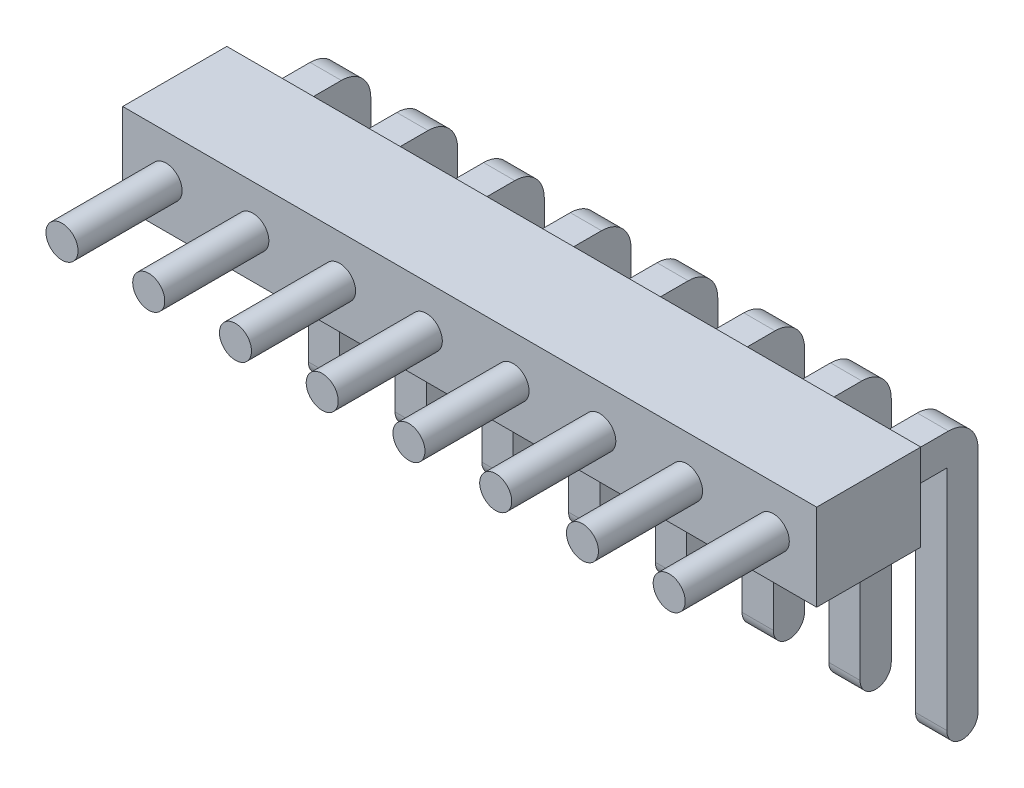
from build123d import *

# Parameters (mm, degrees)
CROQUIS1_W              = 20
CROQUIS1_H              = 2.5
SALIENTE_EXTRUIR1_DEPTH = 3
CROQUIS2_R              = 0.461571169
SALIENTE_EXTRUIR2_DEPTH = 3
MATRIZL1_COUNT          = 8
MATRIZL1_PITCH          = 2.5
SALIENTE_EXTRUIR3_DEPTH = 0.45
MATRIZL2_COUNT          = 8
MATRIZL2_PITCH          = 2.5


with BuildPart() as part:
    # Croquis1 → Saliente-Extruir1 (new body)
    with BuildSketch(Plane.XY):
        Rectangle(CROQUIS1_W, CROQUIS1_H)
    extrude(amount=SALIENTE_EXTRUIR1_DEPTH)

    # Croquis2 → Saliente-Extruir2 (add)
    with BuildSketch(Plane.XY.offset(3)):
        with Locations((-8.75, 0)):
            Circle(CROQUIS2_R)
    saliente_extruir2 = extrude(amount=SALIENTE_EXTRUIR2_DEPTH)

    # MatrizL1: Saliente-Extruir2 ×8
    with Locations(*[(i * MATRIZL1_PITCH, 0, 0) for i in range(1, MATRIZL1_COUNT)]):
        add(saliente_extruir2)

    # Croquis3 → Saliente-Extruir3 (add, symmetric)
    with BuildSketch(Plane(origin=(8.75, 0, 0), x_dir=(0, 0, -1), z_dir=(1, 0, 0))):
        with BuildLine():
            Line((0, -0.45), (1.55, -0.45))
            Line((1.55, -0.45), (1.55, -7))
            ThreePointArc((1.55, -7), (2, -7.45), (2.45, -7))
            Line((2.45, -7), (2.45, -0.4))
            ThreePointArc((2.45, -0.4), (2.201040764, 0.201040764), (1.6, 0.45))
            Line((1.6, 0.45), (0, 0.45))
            Line((0, 0.45), (0, -0.45))
        make_face()
    saliente_extruir3 = extrude(amount=SALIENTE_EXTRUIR3_DEPTH, both=True)

    # MatrizL2: Saliente-Extruir3 ×8
    with Locations(*[(-i * MATRIZL2_PITCH, 0, 0) for i in range(1, MATRIZL2_COUNT)]):
        add(saliente_extruir3)


solid = part.part
